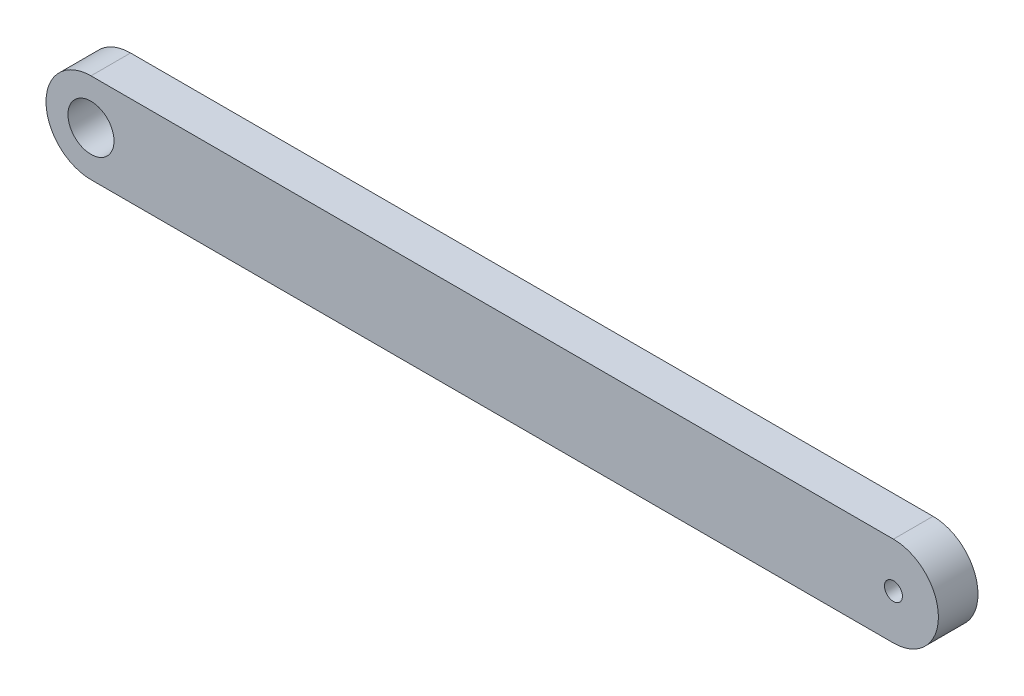
from build123d import *

# Parameters (mm, degrees)
SKETCH1_R           = 1.6
SKETCH1_R_2         = 0.625
BOSS_EXTRUDE1_DEPTH = 2.75


with BuildPart() as part:
    # Sketch1 → Boss-Extrude1 (new body)
    with BuildSketch(Plane.XY):
        with BuildLine():
            Line((0, 3.125), (55.75, 3.125))
            ThreePointArc((55.75, 3.125), (58.875, 0), (55.75, -3.125))
            Line((55.75, -3.125), (0, -3.125))
            ThreePointArc((0, -3.125), (-3.125, 0), (0, 3.125))
        make_face()
        Circle(SKETCH1_R, mode=Mode.SUBTRACT)
        with Locations((55.75, 0)):
            Circle(SKETCH1_R_2, mode=Mode.SUBTRACT)
    extrude(amount=BOSS_EXTRUDE1_DEPTH)


solid = part.part
